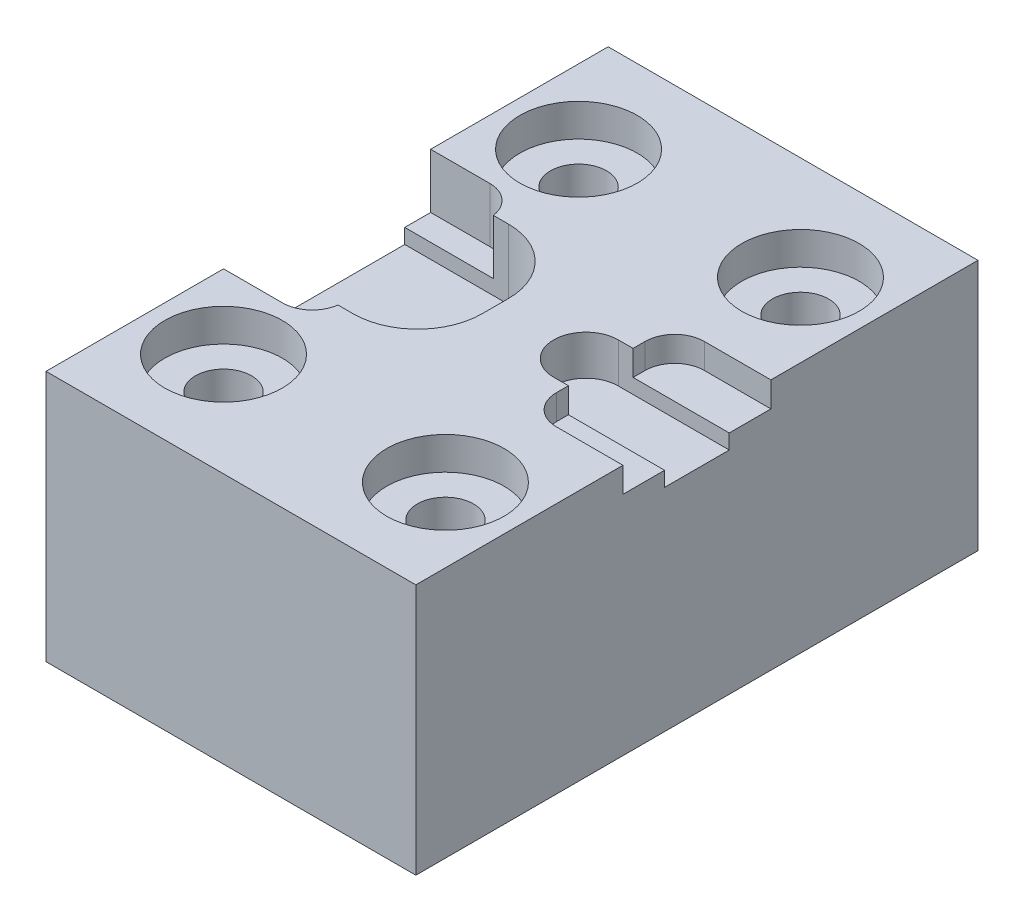
from build123d import *

# Parameters (mm, degrees)
SKETCH1_W                                           = 25
SKETCH1_H                                           = 38
BOSS_EXTRUDE1_DEPTH                                 = 17
CUT_EXTRUDE3_DEPTH                                  = 3.7
CUT_EXTRUDE4_DEPTH                                  = 1.7
CBORE_FOR_6_BINDING_HEAD_MACHINE_SCREW1_D           = 3.7973
CBORE_FOR_6_BINDING_HEAD_MACHINE_SCREW1_CBORE_D     = 7.9375
CBORE_FOR_6_BINDING_HEAD_MACHINE_SCREW1_CBORE_DEPTH = 2.2098
SKETCH12_W                                          = 1
SKETCH12_H                                          = 4.37
SKETCH12_W_2                                        = 6.5
CUT_EXTRUDE5_DEPTH                                  = 2.7
CUT_EXTRUDE6_DEPTH                                  = 4.7


with BuildPart() as part:
    # Sketch1 → Boss-Extrude1 (new body)
    with BuildSketch(Plane(origin=(0, 0, 0), x_dir=(1, 0, 0), z_dir=(0, 1, 0))):
        with Locations((-18481.446731235, 11298.191283293)):
            Rectangle(SKETCH1_W, SKETCH1_H)
    extrude(amount=BOSS_EXTRUDE1_DEPTH)

    # Sketch2 → Cut-Extrude3 (cut)
    with BuildSketch(Plane(origin=(0, 17, 0), x_dir=(1, 0, 0), z_dir=(0, 1, 0))):
        with BuildLine():
            Line((-18493.946731235, 11291.191283293), (-18489.946731235, 11291.191283293))
            ThreePointArc((-18489.946731235, 11291.191283293), (-18488.532517672, 11291.777069731), (-18487.946731235, 11293.191283293))
            Line((-18487.946731235, 11293.191283293), (-18487.946731235, 11303.191283293))
            ThreePointArc((-18487.946731235, 11303.191283293), (-18488.532517672, 11304.605496855), (-18489.946731235, 11305.191283293))
            Line((-18489.946731235, 11305.191283293), (-18493.946731235, 11305.191283293))
            Line((-18493.946731235, 11305.191283293), (-18493.946731235, 11291.191283293))
        make_face()
    extrude(amount=-CUT_EXTRUDE3_DEPTH, mode=Mode.SUBTRACT)

    # Sketch2_6 → Cut-Extrude4 (cut)
    with BuildSketch(Plane(origin=(0, 17, 0), x_dir=(1, 0, 0), z_dir=(0, 1, 0))):
        with BuildLine():
            Line((-18475.446731235, 11301.191283293), (-18475.446731235, 11295.191283293))
            ThreePointArc((-18475.446731235, 11295.191283293), (-18474.860944797, 11293.777069731), (-18473.446731235, 11293.191283293))
            Line((-18473.446731235, 11293.191283293), (-18468.946731235, 11293.191283293))
            Line((-18468.946731235, 11293.191283293), (-18468.946731235, 11303.191283293))
            Line((-18468.946731235, 11303.191283293), (-18473.446731235, 11303.191283293))
            ThreePointArc((-18473.446731235, 11303.191283293), (-18474.860944797, 11302.605496855), (-18475.446731235, 11301.191283293))
        make_face()
    extrude(amount=-CUT_EXTRUDE4_DEPTH, mode=Mode.SUBTRACT)

    # CBORE for _6 Binding Head Machine Screw1 (through all)
    with Locations(Plane(origin=(0, 17, 0), x_dir=(1, 0, 0), z_dir=(0, 1, 0))):
        with Locations((-18488.946731235, 11310.191283293), (-18473.946731235, 11310.191283293), (-18473.946731235, 11286.191283293), (-18488.946731235, 11286.191283293)):
            CounterBoreHole(CBORE_FOR_6_BINDING_HEAD_MACHINE_SCREW1_D / 2, CBORE_FOR_6_BINDING_HEAD_MACHINE_SCREW1_CBORE_D / 2, CBORE_FOR_6_BINDING_HEAD_MACHINE_SCREW1_CBORE_DEPTH)

    # Sketch12 → Cut-Extrude5 (cut)
    with BuildSketch(Plane(origin=(0, 17, 0), x_dir=(1, 0, 0), z_dir=(0, 1, 0))):
        with BuildLine():
            Line((-18476.446731235, 11300.376283293), (-18476.446731235, 11296.006283293))
            ThreePointArc((-18476.446731235, 11296.006283293), (-18478.631731235, 11298.191283293), (-18476.446731235, 11300.376283293))
        make_face()
        with Locations((-18475.946731235, 11298.191283293)):
            Rectangle(SKETCH12_W, SKETCH12_H)
        with Locations((-18472.196731235, 11298.191283293)):
            Rectangle(SKETCH12_W_2, SKETCH12_H)
    extrude(amount=-CUT_EXTRUDE5_DEPTH, mode=Mode.SUBTRACT)

    # Sketch13 → Cut-Extrude6 (cut)
    with BuildSketch(Plane(origin=(0, 17, 0), x_dir=(1, 0, 0), z_dir=(0, 1, 0))):
        with BuildLine():
            ThreePointArc((-18486.936731235, 11303.441283293), (-18483.853745669, 11302.164268859), (-18482.576731235, 11299.081283293))
            Line((-18482.576731235, 11299.081283293), (-18482.576731235, 11297.301283293))
            ThreePointArc((-18482.576731235, 11297.301283293), (-18483.853745669, 11294.218297727), (-18486.936731235, 11292.941283293))
            Line((-18486.936731235, 11292.941283293), (-18486.946731235, 11292.941283293))
            Line((-18486.946731235, 11292.941283293), (-18486.946731235, 11303.441283293))
            Line((-18486.946731235, 11303.441283293), (-18486.936731235, 11303.441283293))
        make_face()
        with BuildLine():
            ThreePointArc((-18487.946731235, 11303.191283293), (-18487.950656716, 11303.316529118), (-18487.962417752, 11303.441283293))
            Line((-18487.962417752, 11303.441283293), (-18493.946731235, 11303.441283293))
            Line((-18493.946731235, 11303.441283293), (-18493.946731235, 11292.941283293))
            Line((-18493.946731235, 11292.941283293), (-18487.962417752, 11292.941283293))
            ThreePointArc((-18487.962417752, 11292.941283293), (-18487.950656716, 11293.066037468), (-18487.946731235, 11293.191283293))
            Line((-18487.946731235, 11293.191283293), (-18487.946731235, 11303.191283293))
        make_face()
        with BuildLine():
            Line((-18486.946731235, 11292.941283293), (-18486.946731235, 11303.441283293))
            Line((-18486.946731235, 11303.441283293), (-18487.962417752, 11303.441283293))
            ThreePointArc((-18487.962417752, 11303.441283293), (-18487.950656716, 11303.316529118), (-18487.946731235, 11303.191283293))
            Line((-18487.946731235, 11303.191283293), (-18487.946731235, 11293.191283293))
            ThreePointArc((-18487.946731235, 11293.191283293), (-18487.950656716, 11293.066037468), (-18487.962417752, 11292.941283293))
            Line((-18487.962417752, 11292.941283293), (-18486.946731235, 11292.941283293))
        make_face()
    extrude(amount=-CUT_EXTRUDE6_DEPTH, mode=Mode.SUBTRACT)


solid = part.part
